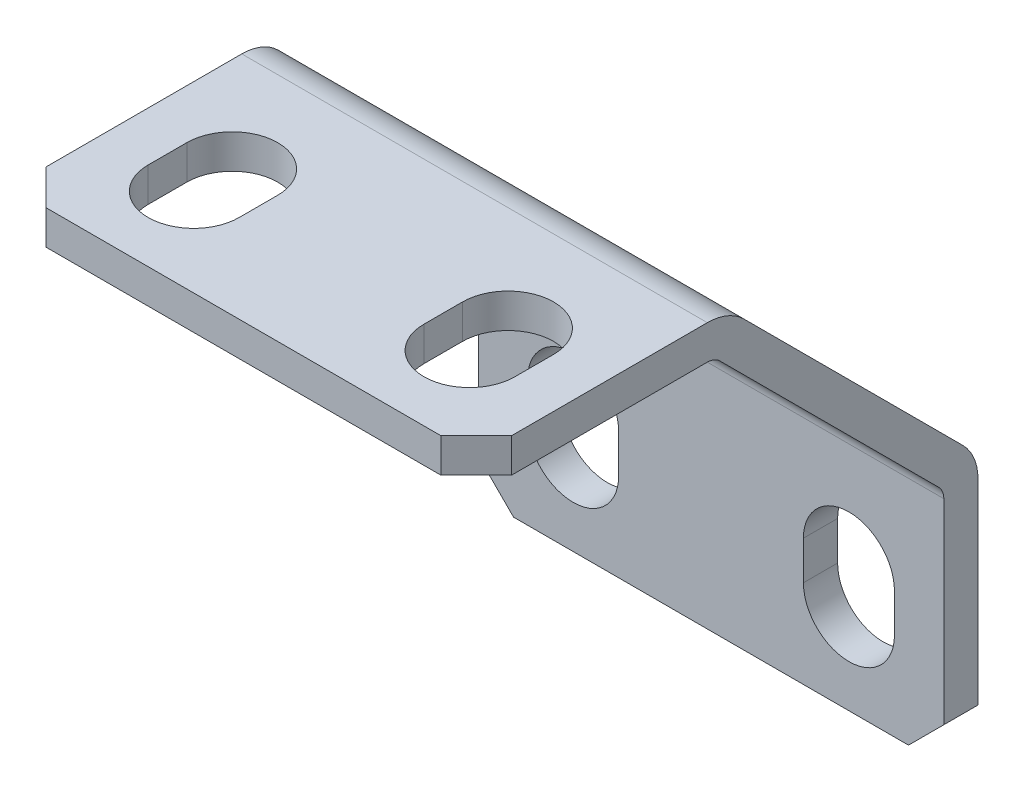
from build123d import *

# Parameters (mm, degrees)
BOSS_EXTRUDE1_DEPTH = 21.4376
CUT_EXTRUDE1_DEPTH  = 22.4376
CUT_EXTRUDE2_DEPTH  = 2.5748
CUT_EXTRUDE3_DEPTH  = 24.107195496
CUT_EXTRUDE4_DEPTH  = 2.5748
CUT_EXTRUDE5_DEPTH  = 24.106279195
CHAMFER1_SIZE       = 1.6256
FILLET1_R           = 0.8128
FILLET2_R           = 2.3876


with BuildPart() as part:
    # Sketch1 → Boss-Extrude1 (new body)
    with BuildSketch(Plane(origin=(10.7188, 0, 0), x_dir=(0, 0, -1), z_dir=(1, 0, 0))):
        Polygon((-23.106279195, 17.785895496), (-23.106279195, -5.3213), (0, -5.3213), (0, 6.310276302), (-11.475619195, 17.785895496), align=None)
    extrude(amount=-BOSS_EXTRUDE1_DEPTH)

    # Sketch2 → Cut-Extrude1 (cut, through all)
    with BuildSketch(Plane.ZY.offset(10.7188)):
        Polygon((23.106279195, -5.3213), (23.106279195, 16.211095496), (12.127922713, 16.211095496), (1.5748, 5.657972783), (1.5748, -5.3213), align=None)
    extrude(amount=-CUT_EXTRUDE1_DEPTH, mode=Mode.SUBTRACT)

    # Sketch3 → Cut-Extrude2 (cut, through all)
    with BuildSketch(Plane.XZ.offset(-16.211095496)):
        with BuildLine():
            Line((-4.2545, 17.272), (-4.2545, 19.05))
            ThreePointArc((-4.2545, 19.05), (-6.35, 21.1455), (-8.4455, 19.05))
            Line((-8.4455, 19.05), (-8.4455, 17.272))
            ThreePointArc((-8.4455, 17.272), (-6.35, 15.1765), (-4.2545, 17.272))
        make_face()
    extrude(amount=-CUT_EXTRUDE2_DEPTH, mode=Mode.SUBTRACT)

    # Sketch4 → Cut-Extrude3 (cut, through all)
    with BuildSketch(Plane(origin=(0, 17.785895496, 0), x_dir=(-1, 0, 0), z_dir=(0, 1, 0))):
        with BuildLine():
            Line((-8.4455, 19.05), (-8.4455, 17.272))
            ThreePointArc((-8.4455, 17.272), (-6.35, 15.1765), (-4.2545, 17.272))
            Line((-4.2545, 17.272), (-4.2545, 19.05))
            ThreePointArc((-4.2545, 19.05), (-6.35, 21.1455), (-8.4455, 19.05))
        make_face()
    extrude(amount=-CUT_EXTRUDE3_DEPTH, mode=Mode.SUBTRACT)

    # Sketch5 → Cut-Extrude4 (cut, through all)
    with BuildSketch(Plane.XY.offset(1.5748)):
        with BuildLine():
            Line((4.2545, 0.513895496), (4.2545, -1.264104504))
            ThreePointArc((4.2545, -1.264104504), (6.35, -3.359604504), (8.4455, -1.264104504))
            Line((8.4455, -1.264104504), (8.4455, 0.513895496))
            ThreePointArc((8.4455, 0.513895496), (6.35, 2.609395496), (4.2545, 0.513895496))
        make_face()
    extrude(amount=-CUT_EXTRUDE4_DEPTH, mode=Mode.SUBTRACT)

    # Sketch6 → Cut-Extrude5 (cut, through all)
    with BuildSketch(Plane(origin=(0, 0, 0), x_dir=(-1, 0, 0), z_dir=(0, 0, -1))):
        with BuildLine():
            Line((8.4455, -1.264104504), (8.4455, 0.513895496))
            ThreePointArc((8.4455, 0.513895496), (6.35, 2.609395496), (4.2545, 0.513895496))
            Line((4.2545, 0.513895496), (4.2545, -1.264104504))
            ThreePointArc((4.2545, -1.264104504), (6.35, -3.359604504), (8.4455, -1.264104504))
        make_face()
    extrude(amount=-CUT_EXTRUDE5_DEPTH, mode=Mode.SUBTRACT)

    # Chamfer1
    chamfer1_edges = [part.edges().sort_by_distance(p)[0] for p in [
        (10.7188, -5.3213, 0.7874),
        (-10.7188, -5.3213, 0.7874),
        (10.7188, 16.998495496, 23.106279195),
        (-10.7188, 16.998495496, 23.106279195),
    ]]
    chamfer(chamfer1_edges, length=CHAMFER1_SIZE)

    # Fillet1
    fillet1_edges = [part.edges().sort_by_distance(p)[0] for p in [
        (0, 5.657972783, 1.5748),
        (0, 16.211095496, 12.127922713),
    ]]
    fillet(fillet1_edges, radius=FILLET1_R)

    # Fillet2
    fillet2_edges = [part.edges().sort_by_distance(p)[0] for p in [
        (0, 17.785895496, 11.475619195),
        (0, 6.310276302, 0),
    ]]
    fillet(fillet2_edges, radius=FILLET2_R)


solid = part.part
